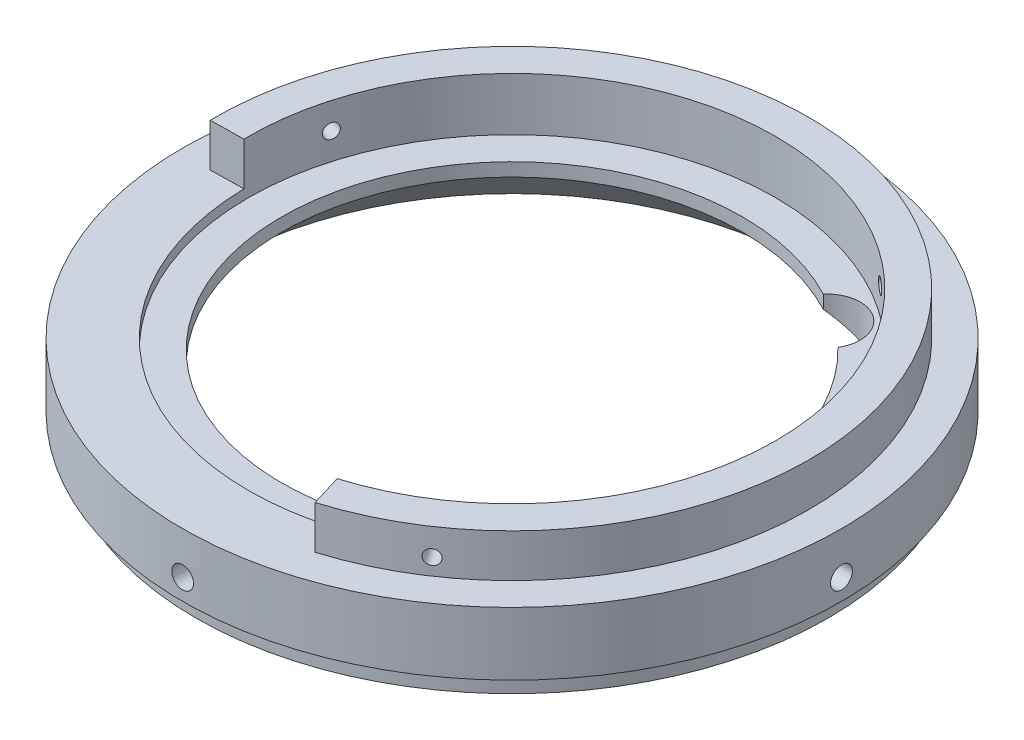
from build123d import *

# Parameters (mm, degrees)
SKETCH5_R          = 1.6425
CUT_EXTRUDE1_DEPTH = 50.7
SKETCH6_R          = 1.095
CUT_EXTRUDE2_DEPTH = 70.421071799
CIRPATTERN1_COUNT  = 4
CUT_EXTRUDE3_DEPTH = 6.5
CIRPATTERN2_COUNT  = 2
CIRPATTERN2_ANGLE  = 110
CIRPATTERN3_COUNT  = 2
CIRPATTERN3_ANGLE  = 110
CUT_EXTRUDE5_REACH = 13.2


with BuildPart() as part:
    # Sketch2 → Revolve1 (revolve)
    with BuildSketch(Plane.XY, mode=Mode.PRIVATE) as revolve1_sk:
        Polygon((49.7, 12.7), (49.7, 3.2004), (47.675, 3.2004), (47.675, 0), (44.7, 0), (34.75, 9.2), (34.75, 11.2), (39.75, 11.2), (39.75, 19.2), (44.75, 19.2), (44.75, 12.7), align=None)
    revolve(revolve1_sk.sketch.rotate(Axis((0, 0, 0), (0, 1, 0)), 90), axis=Axis((0, 0, 0), (0, 1, 0)))  # turned: the seam where the file's is

    # Sketch5 → Cut-Extrude1 (cut, through all)
    with BuildSketch(Plane.XY):
        with Locations(Location((0, 6.35, 0), (0, 0, 89.999999821))):  # turned: the seam where the file's is
            Circle(SKETCH5_R)
    cut_extrude1 = extrude(amount=-CUT_EXTRUDE1_DEPTH, mode=Mode.SUBTRACT)

    # Sketch6 → Cut-Extrude2 (cut, through all)
    with BuildSketch(Plane(origin=(0, 0, 0), x_dir=(0.809016994, 0, 0.587785252), z_dir=(-0.587785252, 0, 0.809016994))):
        with Locations((0, 15.2)):
            Circle(SKETCH6_R)
    cut_extrude2 = extrude(amount=-CUT_EXTRUDE2_DEPTH, mode=Mode.SUBTRACT)

    # CirPattern1: Cut-Extrude1 ×4 about axis
    cirpattern1_axis = Axis((0, 13.335, 0), (0, -1, 0))
    for i in range(1, CIRPATTERN1_COUNT):
        add(cut_extrude1.rotate(cirpattern1_axis, i * 360 / CIRPATTERN1_COUNT), mode=Mode.SUBTRACT)

    # Sketch7 → Cut-Extrude3 (cut)
    with BuildSketch(Plane(origin=(0, 19.2, 0), x_dir=(-1, 0, 0), z_dir=(0, 1, 0))):
        with BuildLine():
            Line((44.743322047, 0.773066741), (39.744068187, 0.686690568))
            ThreePointArc((39.744068187, 0.686690568), (23.364463779, 32.158425526), (-11.628510956, 38.011054089))
            Line((-11.628510956, 38.011054089), (-13.091216736, 42.792318754))
            ThreePointArc((-13.091216736, 42.792318754), (26.30339004, 36.203510498), (44.743322047, 0.773066741))
        make_face()
    extrude(amount=-CUT_EXTRUDE3_DEPTH, mode=Mode.SUBTRACT)

    # CirPattern2: Cut-Extrude2 ×2 about axis
    cirpattern2_axis = Axis((0, 13.335, 0), (0, -1, 0))
    for i in range(1, CIRPATTERN2_COUNT):
        add(cut_extrude2.rotate(cirpattern2_axis, i * CIRPATTERN2_ANGLE / (CIRPATTERN2_COUNT - 1)), mode=Mode.SUBTRACT)

    # CirPattern3: Cut-Extrude2 ×2 about axis
    cirpattern3_axis = Axis((0, 13.335, 0), (0, 1, 0))
    for i in range(1, CIRPATTERN3_COUNT):
        add(cut_extrude2.rotate(cirpattern3_axis, i * CIRPATTERN3_ANGLE / (CIRPATTERN3_COUNT - 1)), mode=Mode.SUBTRACT)

    # Cut-Extrude5: up to this cone (the profile starts outside it)
    cut_extrude5_end = Plane(origin=(0, 11.2, 0), z_dir=(0, -1, 0)).offset(-30.130652266) * Cone(1.082e-06, 82.647306238, 76.417608788, align=(Align.CENTER, Align.CENTER, Align.MIN), mode=Mode.PRIVATE)
    # Sketch8 → Cut-Extrude5 (cut, up to the surface)
    with BuildSketch(Plane(origin=(0, 11.2, 0), x_dir=(1, 0, 0), z_dir=(0, 1, 0)), mode=Mode.PRIVATE) as cut_extrude5_sk1:
        with BuildLine():
            Line((16.181580734, 30.752543715), (24.24702365, 24.892656429))
            ThreePointArc((24.24702365, 24.892656429), (22.923624839, 31.551662781), (16.181580734, 30.752543715))
        make_face()
    cut_extrude5_tool1 = extrude(cut_extrude5_sk1.sketch, amount=-CUT_EXTRUDE5_REACH, mode=Mode.PRIVATE) - cut_extrude5_end
    add(cut_extrude5_tool1.solids().sort_by_distance((21.35698, 11.2, -29.395361))[0], mode=Mode.SUBTRACT)


solid = part.part
